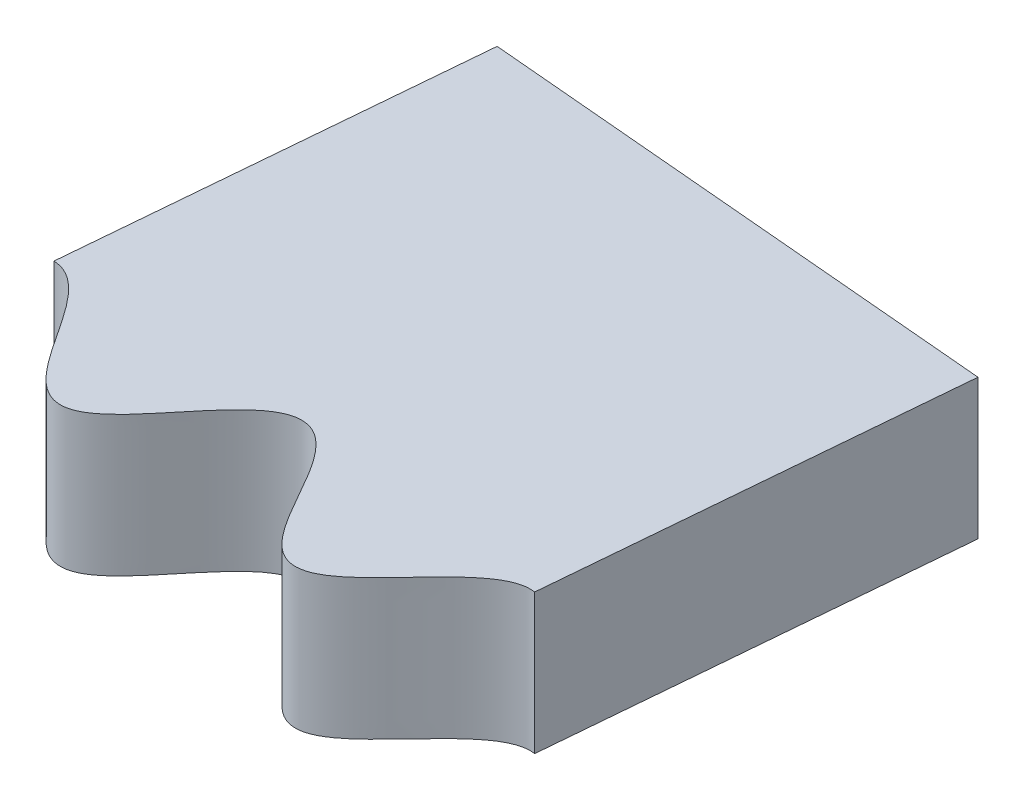
from build123d import *

# Parameters (mm, degrees)
BOSS_EXTRUDE1_DEPTH     = 3
CUT_EXTRUDE2_DEPTH      = 128.314571187
CUT_EXTRUDE2_DEPTH_BACK = 128.314571187
CUT_EXTRUDE1_DEPTH      = 128.295866017
CUT_EXTRUDE1_DEPTH_BACK = 128.295866017
CUT_EXTRUDE3_DEPTH      = 92.026378637
CUT_EXTRUDE3_DEPTH_BACK = 92.026378637


with BuildPart() as part:
    # Sketch1 → Boss-Extrude1 (new body)
    with BuildSketch(Plane(origin=(0, 0, 0), x_dir=(1, 0, 0), z_dir=(0, 1, 0))):
        with BuildLine():
            Line((0, 80.000000001), (0, 90))
            ThreePointArc((0, 90), (63.639610307, 63.639610307), (90, -1e-09))
            Line((90, -1e-09), (79.999999999, -1e-09))
            add(Edge.make_bspline(
                [(79.999999999, -1e-09), (80.041602972, 0.029584336), (80.124672232, 0.088800076), (80.35566562, 0.25503707), (80.580689493, 0.428196261), (80.814260212, 0.628581273), (81.018283416, 0.851310154), (81.156118968, 1.051783348), (81.240847827, 1.272600382), (81.246016609, 1.500136477), (81.179439654, 1.706446625), (81.07209396, 1.882262483), (80.890390613, 2.096864579), (80.621041115, 2.332166665), (80.269616736, 2.584320867), (79.89698522, 2.827334109), (79.578764204, 3.037245113), (79.320425686, 3.220223571), (79.121721967, 3.374962868), (78.93587352, 3.543581035), (78.772636972, 3.733120424), (78.655258727, 3.951437655), (78.623837197, 4.193153248), (78.683771621, 4.421996137), (78.795973828, 4.620716318), (78.984584589, 4.861193345), (79.260256827, 5.129313496), (79.614056753, 5.426162178), (80.034933667, 5.76565788), (80.383334353, 6.06905351), (80.649167813, 6.347378107), (80.823997795, 6.598345884), (80.921414714, 6.805042909), (80.956081181, 7.009003624), (80.930346945, 7.189278287), (80.859213533, 7.366686325), (80.74543326, 7.533712707), (80.581106495, 7.700842654), (80.324453775, 7.904792798), (79.998299986, 8.115192141), (79.608972322, 8.337012127), (79.219952007, 8.552844572), (78.892674068, 8.748998278), (78.645925583, 8.921468469), (78.475904629, 9.06187581), (78.334858688, 9.209053991), (78.228156562, 9.363513239), (78.155173948, 9.554557886), (78.14975415, 9.776640253), (78.224125666, 10.002339676), (78.352006258, 10.217315497), (78.505739265, 10.415655269), (78.674556444, 10.602546037), (78.897195956, 10.827604872), (79.174131916, 11.089585329), (79.498903567, 11.393613439), (79.801202691, 11.702961073), (80.025600841, 11.981460372), (80.167277182, 12.224354961), (80.242468586, 12.416137885), (80.271819819, 12.628249292), (80.229522961, 12.846179845), (80.114958566, 13.043632677), (79.954763586, 13.212416243), (79.720296673, 13.397936952), (79.407072243, 13.587360316), (79.021163378, 13.781984942), (78.568623274, 13.992615123), (78.180049511, 14.181676141), (77.861870541, 14.362378523), (77.620410558, 14.538567291), (77.4524268, 14.699555404), (77.324178924, 14.896997351), (77.274027441, 15.128431223), (77.311347079, 15.36116915), (77.402874813, 15.575335254), (77.557886287, 15.830947411), (77.78360241, 16.118944367), (78.072308852, 16.440385908), (78.413020362, 16.805019859), (78.698748429, 17.129144261), (78.919925661, 17.420606013), (79.070830749, 17.678529711), (79.160125782, 17.893107887), (79.199493517, 18.117666805), (79.166110239, 18.337116843), (79.066113718, 18.526654787), (78.928041203, 18.679890365), (78.758095072, 18.815824297), (78.563403249, 18.937780224), (78.292286179, 19.078874501), (77.942082175, 19.230391028), (77.586564332, 19.368174353), (77.231347041, 19.506941755), (76.94020429, 19.631303179), (76.713043974, 19.740085409), (76.495059022, 19.864369093), (76.293843643, 20.012665132), (76.133111284, 20.191926835), (76.044903013, 20.40380645), (76.037591525, 20.619301184), (76.082831408, 20.816111266), (76.1668516, 21.018822902), (76.283150762, 21.22615829), (76.464160702, 21.496087871), (76.715848982, 21.822467791), (77.019348776, 22.195304006), (77.308333885, 22.569732877), (77.525684963, 22.902766036), (77.662974453, 23.192900921), (77.732396667, 23.428451636), (77.738105043, 23.673858139), (77.654032855, 23.901813946), (77.501220488, 24.084150894), (77.316617591, 24.225367665), (77.056961817, 24.373272722), (76.719688349, 24.515101469), (76.310177073, 24.652935314), (75.832796036, 24.798363031), (75.42204772, 24.932385667), (75.082573555, 25.068940615), (74.820523526, 25.212801381), (74.634175149, 25.352510829), (74.485486428, 25.53540796), (74.41320195, 25.760911316), (74.425546896, 25.996024996), (74.490531041, 26.219436671), (74.611547136, 26.492750611), (74.796747016, 26.808332949), (75.038731258, 27.166351475), (75.325327393, 27.575032615), (75.562221961, 27.936536917), (75.738770592, 28.257194577), (75.849064541, 28.535093682), (75.90340568, 28.761362027), (75.90389494, 28.989643393), (75.831559817, 29.199525217), (75.700085201, 29.368543468), (75.539076071, 29.497036648), (75.294933474, 29.636551369), (74.9613493, 29.76553974), (74.544876821, 29.882293138), (74.11160217, 29.9832033), (73.740778506, 30.071617174), (73.435437361, 30.155203683), (73.195792994, 30.232650392), (72.963481769, 30.327535724), (72.7452633, 30.449814302), (72.560294939, 30.614819669), (72.448096758, 30.831211232), (72.426147815, 31.066751986), (72.463617097, 31.291863289), (72.55860525, 31.582346457), (72.725949925, 31.928582442), (72.956884876, 32.328535659), (73.236265438, 32.791505648), (73.459887575, 33.195764335), (73.614496696, 33.548224303), (73.692947106, 33.843852247), (73.71379452, 34.071402464), (73.67661167, 34.274919473), (73.590771832, 34.435520616), (73.463251167, 34.577900582), (73.299206297, 34.695938894), (73.08762784, 34.796786609), (72.776698116, 34.900656654), (72.398252994, 34.986816198), (71.956537757, 35.062100899), (71.517159194, 35.13186427), (71.142530011, 35.204252813), (70.851674001, 35.281928827), (70.643884426, 35.355717978), (70.461006694, 35.445779676), (70.307911319, 35.554429614), (70.173988978, 35.708991335), (70.09293939, 35.915826817), (70.085632007, 36.153351456), (70.132274394, 36.399100387), (70.208899969, 36.638058592), (70.303615819, 36.871417343), (70.435853871, 37.159050668), (70.606485955, 37.499949447), (70.807687742, 37.896720865), (70.985952875, 38.290804944), (71.101565791, 38.629257368), (71.151623161, 38.905959782), (71.156686345, 39.111893756), (71.111721108, 39.321251993), (70.997438424, 39.511573348), (70.822250262, 39.657934986), (70.613988842, 39.761749747), (70.330210194, 39.855889782), (69.971088903, 39.926760455), (69.541887647, 39.977659174), (69.044599286, 40.02080897), (68.614796712, 40.065568159), (68.254002427, 40.126549237), (67.966844156, 40.209528344), (67.75392988, 40.303353858), (67.565887175, 40.44502524), (67.439605148, 40.645349126), (67.395073085, 40.876815305), (67.407831866, 41.109369945), (67.466070637, 41.402583831), (67.579673265, 41.750411958), (67.741029898, 42.151211512), (67.93648042, 42.610385738), (68.094122342, 43.012687463), (68.202270425, 43.36221969), (68.255872092, 43.656199091), (68.266354226, 43.888385505), (68.224901916, 44.122650501), (68.104318197, 44.333580702), (67.912656635, 44.486952091), (67.68759058, 44.585180671), (67.37708638, 44.666505929), (66.9822576, 44.714074933), (66.509672397, 44.733377734), (66.028977379, 44.740537903), (65.617173747, 44.757526464), (65.294044745, 44.792372194), (65.060460963, 44.836554487), (64.851167702, 44.902491813), (64.671322796, 44.994343134), (64.510943987, 45.138461404), (64.405333968, 45.342226451), (64.371328306, 45.580581783), (64.387065702, 45.830044563), (64.431976903, 46.076918736), (64.494660716, 46.320857503), (64.586537291, 46.623823772), (64.708564568, 46.985133971), (64.831538881, 47.346041853), (64.940577283, 47.71170663), (65.006763489, 48.010088009), (65.03848532, 48.237622357), (65.043593155, 48.455185292), (65.014959193, 48.659452906), (64.93404123, 48.857887328), (64.787391105, 49.024520168), (64.590063902, 49.138706423), (64.36828974, 49.208230652), (64.073708805, 49.258420806), (63.708266165, 49.276337219), (63.276310007, 49.26579997), (62.777979057, 49.239181997), (62.346163627, 49.224638672), (61.980457633, 49.236850965), (61.685007905, 49.282409614), (61.462114258, 49.34995862), (61.259838062, 49.470971174), (61.114786181, 49.658152265), (61.045973022, 49.883309075), (61.03062685, 50.115473264), (61.050865909, 50.413694299), (61.116961353, 50.773586782), (61.221902611, 51.192777635), (61.351437703, 51.674833937), (61.450404027, 52.095559577), (61.506634094, 52.457262402), (61.515229412, 52.756124891), (61.488905048, 52.98733335), (61.411287976, 53.202015002), (61.271531383, 53.374499334), (61.09017801, 53.48835757), (60.894931662, 53.554033298), (60.617795822, 53.601632566), (60.260212614, 53.608749479), (59.828924485, 53.576019809), (59.387266184, 53.522655685), (59.008566597, 53.478908387), (58.693051506, 53.453021191), (58.441371129, 53.44383409), (58.19061729, 53.453542019), (57.943737267, 53.493811184), (57.713488707, 53.585602607), (57.53404662, 53.750570113), (57.432861723, 53.964399082), (57.391078572, 54.18874962), (57.380987624, 54.494202797), (57.419819196, 54.876792291), (57.500037766, 55.331612229), (57.604219792, 55.862211265), (57.676098978, 56.318580299), (57.700822788, 56.702652386), (57.67345467, 57.007304083), (57.615149416, 57.228200702), (57.493634223, 57.436206161), (57.293851917, 57.590987617), (57.045157934, 57.669958122), (56.778794714, 57.69580622), (56.4509512, 57.686944216), (56.065936692, 57.638539129), (55.625064093, 57.558166278), (55.188350987, 57.473471058), (54.811542785, 57.413351266), (54.511665947, 57.386868812), (54.291168979, 57.385138594), (54.088517381, 57.407221192), (53.907494346, 57.456957059), (53.728785281, 57.556393424), (53.581881676, 57.723034603), (53.493776775, 57.943735485), (53.453555195, 58.190616576), (53.443831164, 58.44137133), (53.453021555, 58.693051554), (53.478908286, 59.008566544), (53.522655747, 59.387266221), (53.576019764, 59.828924459), (53.608749501, 60.260212626), (53.601632559, 60.617795818), (53.5540333, 60.894931663), (53.48835757, 61.09017801), (53.374499335, 61.271531383), (53.202015003, 61.411287976), (52.98733335, 61.488905048), (52.756124892, 61.515229412), (52.457262402, 61.506634094), (52.095559577, 61.450404027), (51.674833937, 61.351437703), (51.192777635, 61.221902611), (50.773586782, 61.116961352), (50.413694299, 61.050865908), (50.115473264, 61.03062685), (49.883309075, 61.045973021), (49.658152265, 61.114786181), (49.470971173, 61.259838061), (49.349958626, 61.462114259), (49.282409587, 61.685007899), (49.236851076, 61.980457657), (49.224638401, 62.346163568), (49.239182517, 62.77797917), (49.265799096, 63.276309817), (49.276338753, 63.708266493), (49.258417646, 64.07370817), (49.208239861, 64.368291293), (49.138677413, 64.590060254), (49.019601636, 64.796019817), (48.834147627, 64.952987309), (48.601588568, 65.031557157), (48.356499504, 65.046884704), (48.036906122, 65.017106759), (47.649618873, 64.926767604), (47.198932099, 64.783272645), (46.744777615, 64.625593625), (46.351998351, 64.500712512), (46.03643847, 64.42294016), (45.80183028, 64.384567576), (45.582607053, 64.374945884), (45.38219312, 64.399747312), (45.182194986, 64.480321404), (45.01326228, 64.635677161), (44.899785085, 64.848027286), (44.829252104, 65.087828126), (44.787018888, 65.3351745), (44.762490433, 65.585841086), (44.745205605, 65.901959893), (44.736298371, 66.283216207), (44.728418661, 66.664418373), (44.705816522, 67.045324195), (44.66595877, 67.348347991), (44.61794621, 67.573009844), (44.548335098, 67.779199111), (44.451564338, 67.961354489), (44.307657755, 68.120146277), (44.112859927, 68.226572631), (43.888379011, 68.266382734), (43.656200781, 68.255862909), (43.362219206, 68.202273611), (43.01268768, 68.094120789), (42.610385617, 67.936481307), (42.151211584, 67.741029371), (41.750411921, 67.57967354), (41.402583847, 67.466070525), (41.109369942, 67.407831894), (40.876815306, 67.395073079), (40.645349126, 67.439605149), (40.445025241, 67.565887174), (40.303353858, 67.75392988), (40.209528344, 67.966844156), (40.126549237, 68.254002428), (40.06556816, 68.614796712), (40.02080897, 69.044599286), (39.977659175, 69.541887647), (39.926760456, 69.971088903), (39.855889782, 70.330210194), (39.761749748, 70.613988842), (39.657934987, 70.822250262), (39.511573348, 70.997438424), (39.321251993, 71.111721108), (39.111893756, 71.156686345), (38.905959782, 71.151623158), (38.629257369, 71.101565799), (38.29080494, 70.98595285), (37.896720874, 70.807687792), (37.499949433, 70.606485884), (37.159050683, 70.435853984), (36.871417423, 70.30361546), (36.638057403, 70.208902651), (36.399105564, 70.132262256), (36.153341363, 70.085664952), (35.905583975, 70.09317103), (35.680541359, 70.186816969), (35.512324844, 70.3531432), (35.396329122, 70.549673066), (35.282375593, 70.833253855), (35.188012021, 71.20605156), (35.107835239, 71.660878865), (35.024258761, 72.195111216), (34.935715699, 72.648541959), (34.827588091, 73.017907706), (34.697673456, 73.29482621), (34.567333345, 73.482459562), (34.382004358, 73.636360113), (34.141332024, 73.713477531), (33.88062662, 73.702627181), (33.621486498, 73.635814861), (33.31644535, 73.515358216), (32.971205573, 73.338189596), (32.584409979, 73.111876511), (32.203001367, 72.882924358), (31.86947966, 72.697554239), (31.596745141, 72.570104953), (31.390137537, 72.493064675), (31.192154633, 72.4445046), (31.005037951, 72.429327507), (30.803097128, 72.461645018), (30.608058255, 72.567992509), (30.449782586, 72.745249845), (30.327548, 72.963486109), (30.23265072, 73.195787647), (30.155191569, 73.435455455), (30.071652604, 73.740727262), (29.983124112, 74.111716393), (29.882440532, 74.54466436), (29.751508784, 75.010917506), (29.598303142, 75.389689457), (29.409589028, 75.668067135), (29.199483961, 75.831619263), (28.989655267, 75.903877833), (28.761359059, 75.903409957), (28.535094331, 75.849063606), (28.257194316, 75.73877097), (27.936537077, 75.562221732), (27.575032514, 75.325327539), (27.166351538, 75.038731168), (26.808332916, 74.796747064), (26.492750625, 74.611547117), (26.219436668, 74.490531046), (25.996024997, 74.425546895), (25.760911317, 74.413201951), (25.535407961, 74.485486428), (25.352510829, 74.63417515), (25.212801381, 74.820523526), (25.068940616, 75.082573555), (24.932385667, 75.42204772), (24.798363032, 75.832796036), (24.652935315, 76.310177073), (24.515101469, 76.719688349), (24.373272722, 77.056961817), (24.225367665, 77.316617591), (24.084150895, 77.501220489), (23.901813947, 77.654032856), (23.673858139, 77.738105043), (23.428451636, 77.732396667), (23.192900921, 77.662974453), (22.902766036, 77.525684963), (22.569732877, 77.308333886), (22.195304007, 77.019348776), (21.822467791, 76.715848983), (21.496087871, 76.464160702), (21.226158291, 76.283150762), (21.018822902, 76.166851601), (20.816111267, 76.082831408), (20.619301185, 76.037591525), (20.403806451, 76.044903014), (20.191926836, 76.133111284), (20.012665133, 76.293843643), (19.864369094, 76.495059023), (19.74008541, 76.713043975), (19.631303179, 76.94020429), (19.506941755, 77.231347041), (19.368174353, 77.586564332), (19.230391029, 77.942082175), (19.078874502, 78.292286179), (18.937780224, 78.563403249), (18.815824297, 78.758095072), (18.679890366, 78.928041203), (18.526654788, 79.066113718), (18.337116844, 79.166110239), (18.117666805, 79.199493518), (17.893107888, 79.160125783), (17.678529711, 79.070830749), (17.420606014, 78.919925661), (17.129144261, 78.69874843), (16.80501986, 78.413020362), (16.440385908, 78.072308852), (16.118944367, 77.78360241), (15.830947412, 77.557886287), (15.575335254, 77.402874813), (15.36116915, 77.311347079), (15.128431224, 77.274027441), (14.896997351, 77.324178924), (14.699555405, 77.452426801), (14.538567291, 77.620410559), (14.362378523, 77.861870542), (14.181676142, 78.180049511), (13.992615123, 78.568623275), (13.781984943, 79.021163379), (13.587360317, 79.407072244), (13.397936953, 79.720296673), (13.212416243, 79.954763586), (13.043632678, 80.114958566), (12.846179845, 80.229522961), (12.628249293, 80.271819819), (12.416137885, 80.242468587), (12.224354962, 80.16727718), (11.981460371, 80.02560085), (11.702961078, 79.801202666), (11.39361343, 79.498903618), (11.089585341, 79.174131844), (10.827604848, 78.897196068), (10.602546235, 78.674556134), (10.415653235, 78.505741379), (10.217324513, 78.351996623), (10.002318924, 78.224153173), (9.766935904, 78.146468561), (9.523436221, 78.157497852), (9.308477482, 78.256259948), (9.132259985, 78.401264738), (8.928188352, 78.628769112), (8.712011278, 78.946810118), (8.481109641, 79.346785914), (8.219855229, 79.82021526), (7.9815695, 80.216017294), (7.753632291, 80.526125704), (7.536840699, 80.741910627), (7.350186886, 80.873649116), (7.12339681, 80.954882885), (6.870865132, 80.945032435), (6.629587671, 80.845676267), (6.40894144, 80.694245416), (6.211128052, 80.519009442), (6.029457649, 80.332101133), (5.816457311, 80.09190662), (5.614074206, 79.846852317), (5.413538428, 79.600329501), (5.208468822, 79.357528606), (5.038559084, 79.168310476), (4.87078477, 79.000324827), (4.702993216, 78.857255698), (4.533557773, 78.743911453), (4.362916364, 78.665652164), (4.162100833, 78.626952836), (3.942451292, 78.660179508), (3.7330952, 78.772613498), (3.543591665, 78.935881709), (3.374959826, 79.12171778), (3.2202265, 79.320435777), (3.037237307, 79.578735654), (2.827352032, 79.897050875), (2.619008751, 80.21628), (2.39906785, 80.527958221), (2.206288538, 80.765002448), (2.04825606, 80.931612231), (1.882258293, 81.072078605), (1.706447202, 81.179441768), (1.500136496, 81.246016677), (1.27260037, 81.240847779), (1.051783338, 81.156118931), (0.851310168, 81.01828346), (0.62858125, 80.814260161), (0.428196313, 80.580689584), (0.255036967, 80.355665447), (0.088800204, 80.124672445), (0.029584337, 80.041602974), (0, 80.000000001)],
                knots=[0.077847526, 0.077847526, 0.077847526, 0.077847526, 0.077847526, 0.079019089, 0.080190652, 0.082533779, 0.083705342, 0.084876905, 0.086048468, 0.087220031, 0.088210559, 0.089201086, 0.090191614, 0.091182141, 0.093644505, 0.096106868, 0.098569231, 0.099800413, 0.101031595, 0.102239172, 0.10344675, 0.104654328, 0.105861906, 0.106959082, 0.108056259, 0.109153436, 0.110250612, 0.112868894, 0.115487176, 0.118105457, 0.120723739, 0.12182072, 0.122917702, 0.124014684, 0.125111666, 0.125758009, 0.126404352, 0.127697039, 0.128989725, 0.130282411, 0.132745478, 0.135208544, 0.13767161, 0.138903144, 0.140134677, 0.141036522, 0.141938367, 0.142840212, 0.143742057, 0.144949635, 0.146157213, 0.147364791, 0.148572368, 0.14980355, 0.151034732, 0.153497095, 0.155959458, 0.158421822, 0.159412349, 0.160402877, 0.161393404, 0.162383932, 0.163504677, 0.164625422, 0.165746167, 0.166866913, 0.169284472, 0.171702032, 0.174119591, 0.176537151, 0.177658304, 0.178779457, 0.17990061, 0.181021763, 0.182142924, 0.183264084, 0.184385245, 0.185506405, 0.187923426, 0.190340446, 0.192757467, 0.195174487, 0.196294788, 0.197415089, 0.198535391, 0.199655692, 0.200646634, 0.201637576, 0.202628519, 0.203619461, 0.204850906, 0.206082351, 0.208545241, 0.211008132, 0.212239577, 0.213471022, 0.214678537, 0.215886051, 0.217093566, 0.21830108, 0.219270311, 0.220239542, 0.221208773, 0.222178004, 0.223508612, 0.22483922, 0.227500436, 0.230161653, 0.232822869, 0.234003972, 0.235185075, 0.236366178, 0.23754728, 0.238667582, 0.239787883, 0.240908184, 0.242028485, 0.244445506, 0.246862526, 0.249279546, 0.251696567, 0.252817727, 0.253938888, 0.255060048, 0.256181209, 0.257302362, 0.258423515, 0.259544668, 0.260665822, 0.263083381, 0.265500941, 0.2679185, 0.27033606, 0.271456805, 0.27257755, 0.273698295, 0.274819041, 0.275809568, 0.276800096, 0.277790623, 0.278781151, 0.281243514, 0.283705877, 0.28616824, 0.287399422, 0.288630604, 0.289838182, 0.291045759, 0.292253337, 0.293460915, 0.294558091, 0.295655268, 0.296752445, 0.297849622, 0.300467903, 0.303086185, 0.305704466, 0.308322748, 0.30941973, 0.310516712, 0.311613693, 0.312710675, 0.313357018, 0.314003362, 0.315296048, 0.316588734, 0.317881421, 0.320344487, 0.322807553, 0.32527062, 0.326502153, 0.327733686, 0.328635531, 0.329537376, 0.330439222, 0.331341067, 0.332548644, 0.333756222, 0.3349638, 0.336171378, 0.337402559, 0.338633741, 0.341096104, 0.343558468, 0.346020831, 0.347011358, 0.348001886, 0.348992413, 0.349982941, 0.351103686, 0.352224431, 0.353345177, 0.354465922, 0.356883481, 0.359301041, 0.3617186, 0.36413616, 0.365257313, 0.366378466, 0.367499619, 0.368620773, 0.369741933, 0.370863094, 0.371984254, 0.373105415, 0.375522435, 0.377939455, 0.380356476, 0.382773496, 0.383893797, 0.385014099, 0.3861344, 0.387254701, 0.388435804, 0.389616907, 0.39079801, 0.391979112, 0.394640329, 0.397301545, 0.399962762, 0.40129337, 0.402623978, 0.403593209, 0.40456244, 0.40553167, 0.406500901, 0.407708416, 0.40891593, 0.410123445, 0.41133096, 0.412562405, 0.41379385, 0.41625674, 0.41871963, 0.419951075, 0.42118252, 0.422173463, 0.423164405, 0.424155347, 0.42514629, 0.426266591, 0.427386892, 0.428507193, 0.429627494, 0.432044515, 0.434461535, 0.436878556, 0.439295576, 0.440416737, 0.441537897, 0.442659058, 0.443780218, 0.444901371, 0.446022525, 0.447143678, 0.448264831, 0.45068239, 0.45309995, 0.455517509, 0.457935069, 0.459055814, 0.460176559, 0.461297305, 0.46241805, 0.463408577, 0.464399105, 0.465389632, 0.46638016, 0.468842523, 0.471304886, 0.47376725, 0.474998431, 0.476229613, 0.477437191, 0.478644769, 0.479852346, 0.481059924, 0.482157101, 0.483254277, 0.484351454, 0.485448631, 0.488066912, 0.490685194, 0.493303476, 0.495921757, 0.497018739, 0.498115721, 0.499212703, 0.500309685, 0.501602371, 0.502895057, 0.504187743, 0.50548043, 0.507943496, 0.510406563, 0.512869629, 0.514101162, 0.515332695, 0.51623454, 0.517136386, 0.518038231, 0.518940076, 0.520147654, 0.521355231, 0.522562809, 0.523770387, 0.525001569, 0.52623275, 0.528695114, 0.531157477, 0.53361984, 0.534610368, 0.535600895, 0.536591423, 0.53758195, 0.538702695, 0.539823441, 0.540944186, 0.542064931, 0.544482491, 0.54690005, 0.54931761, 0.551735169, 0.552856322, 0.553977475, 0.555098629, 0.556219782, 0.557340942, 0.558462103, 0.559583263, 0.560704424, 0.563121444, 0.565538465, 0.567955485, 0.570372506, 0.571492807, 0.572613108, 0.573733409, 0.57485371, 0.576034813, 0.577215916, 0.578397019, 0.579578122, 0.582239338, 0.584900554, 0.587561771, 0.588892379, 0.590222987, 0.591192218, 0.592161449, 0.59313068, 0.59409991, 0.595307425, 0.59651494, 0.597722454, 0.598929969, 0.600161414, 0.601392859, 0.603855749, 0.60631864, 0.607550085, 0.60878153, 0.609772472, 0.610763414, 0.611754357, 0.612745299, 0.6138656, 0.614985901, 0.616106203, 0.617226504, 0.619643524, 0.622060545, 0.624477565, 0.626894585, 0.628015746, 0.629136906, 0.630258067, 0.631379227, 0.632500381, 0.633621534, 0.634742687, 0.63586384, 0.6382814, 0.640698959, 0.643116519, 0.645534078, 0.646654823, 0.647775569, 0.648896314, 0.650017059, 0.651007587, 0.651998114, 0.652988642, 0.653979169, 0.656441532, 0.658903896, 0.661366259, 0.662597441, 0.663828622, 0.6650362, 0.666243778, 0.667451356, 0.668658933, 0.66975611, 0.670853287, 0.671950463, 0.67304764, 0.675665922, 0.678284203, 0.680902485, 0.683520766, 0.684617748, 0.68571473, 0.686811712, 0.687908694, 0.68920138, 0.690494066, 0.691786753, 0.693079439, 0.695542505, 0.698005572, 0.700468638, 0.701700171, 0.702931705, 0.70383355, 0.704735395, 0.70563724, 0.706539085, 0.707746663, 0.708954241, 0.710161818, 0.711369396, 0.712600578, 0.71383176, 0.716294123, 0.718756486, 0.721218849, 0.723199904, 0.724190432, 0.725180959, 0.726301705, 0.72742245, 0.728543195, 0.72966394, 0.7320815, 0.734499059, 0.736916619, 0.739334178, 0.740455332, 0.741576485, 0.742697638, 0.743818791, 0.744939952, 0.746061112, 0.747182273, 0.748303433, 0.750720454, 0.753137474, 0.755554494, 0.757971515, 0.759091816, 0.760212117, 0.761332418, 0.76245272, 0.763633822, 0.764814925, 0.765996028, 0.767177131, 0.769838347, 0.772499564, 0.77516078, 0.776491388, 0.777821996, 0.778791227, 0.779760458, 0.780729689, 0.78169892, 0.782906434, 0.784113949, 0.785321463, 0.786528978, 0.787760423, 0.788991868, 0.791454759, 0.793917649, 0.795149094, 0.796380539, 0.797371481, 0.798362424, 0.799353366, 0.800344308, 0.801464609, 0.802584911, 0.803705212, 0.804825513, 0.807242533, 0.809659554, 0.812076574, 0.814493595, 0.815614755, 0.816735916, 0.817857076, 0.818978237, 0.82009939, 0.821220543, 0.822341696, 0.823462849, 0.825880409, 0.828297968, 0.830715528, 0.833133087, 0.834253833, 0.835374578, 0.836495323, 0.837616068, 0.838606596, 0.839597123, 0.840587651, 0.841578178, 0.844040542, 0.846502905, 0.848965268, 0.85019645, 0.851427632, 0.852635209, 0.853842787, 0.855050365, 0.856257943, 0.857355119, 0.858452296, 0.859549473, 0.860646649, 0.863264931, 0.865883212, 0.868501494, 0.871119776, 0.872216757, 0.873313739, 0.874410721, 0.875507703, 0.876800389, 0.878093076, 0.879385762, 0.880678448, 0.881909981, 0.883141515, 0.885604581, 0.886836114, 0.888067647, 0.889299181, 0.890530714, 0.891432559, 0.892334404, 0.893236249, 0.894138094, 0.895345672, 0.89655325, 0.897760828, 0.898968405, 0.900199587, 0.901430769, 0.903893132, 0.906355495, 0.907586677, 0.908817859, 0.909808386, 0.910798914, 0.911789441, 0.912779969, 0.913951532, 0.915123095, 0.916294658, 0.917466221, 0.919809348, 0.920980911, 0.922152474, 0.922152474, 0.922152474, 0.922152474, 0.922152474], degree=4))
        make_face()
    extrude(amount=BOSS_EXTRUDE1_DEPTH)

    # Sketch3 → Cut-Extrude2 (cut, two sides)
    with BuildSketch(Plane(origin=(0, 3, 0), x_dir=(1, 0, 0), z_dir=(0, 1, 0))) as cut_extrude2_sk:
        with BuildLine():
            Line((1.418002739, 81.237322491), (2.182322522, 89.973537601))
            ThreePointArc((2.182322522, 89.973537601), (1.091241478, 89.993384157), (0, 90))
            Line((0, 90), (0, 80.000000001))
            add(Edge.make_bspline(
                [(0, 80.000000001), (0.029584337, 80.041602974), (0.088800204, 80.124672445), (0.255036967, 80.355665447), (0.428196313, 80.580689584), (0.62858125, 80.814260161), (0.851310168, 81.01828346), (1.051783338, 81.156118931), (1.22708417, 81.223382935), (1.351218774, 81.238056655), (1.41481254, 81.237377239), (1.418002739, 81.237322491)],
                knots=[0.077847526, 0.077847526, 0.077847526, 0.077847526, 0.077847526, 0.079019089, 0.080190652, 0.082533779, 0.083705342, 0.084876905, 0.086048468, 0.087220031, 0.087281915, 0.087281915, 0.087281915, 0.087281915, 0.087281915], degree=4))
        make_face()
    extrude(amount=CUT_EXTRUDE2_DEPTH, mode=Mode.SUBTRACT)
    extrude(cut_extrude2_sk.sketch, amount=-CUT_EXTRUDE2_DEPTH_BACK, mode=Mode.SUBTRACT)

    # Sketch2 → Cut-Extrude1 (cut, two sides)
    with BuildSketch(Plane(origin=(0, 3, 0), x_dir=(1, 0, 0), z_dir=(0, 1, 0))) as cut_extrude1_sk:
        with BuildLine():
            Line((13.474573019, 88.985593677), (12.710253656, 80.249384336))
            add(Edge.make_bspline(
                [(12.710253656, 80.249384336), (12.713404224, 80.248884632), (12.773562237, 80.238943153), (12.888306084, 80.205080835), (13.043632678, 80.114958566), (13.212416243, 79.954763586), (13.397936953, 79.720296673), (13.587360317, 79.407072244), (13.781984943, 79.021163379), (13.992615123, 78.568623275), (14.181676142, 78.180049511), (14.362378523, 77.861870542), (14.538567291, 77.620410559), (14.699555405, 77.452426801), (14.896997351, 77.324178924), (15.128431224, 77.274027441), (15.36116915, 77.311347079), (15.575335254, 77.402874813), (15.830947412, 77.557886287), (16.118944367, 77.78360241), (16.440385908, 78.072308852), (16.80501986, 78.413020362), (17.129144261, 78.69874843), (17.420606014, 78.919925661), (17.678529711, 79.070830749), (17.893107888, 79.160125783), (18.117666805, 79.199493518), (18.337116844, 79.166110239), (18.526654788, 79.066113718), (18.679890366, 78.928041203), (18.815824297, 78.758095072), (18.937780224, 78.563403249), (19.078874502, 78.292286179), (19.230391029, 77.942082175), (19.368174353, 77.586564332), (19.506941755, 77.231347041), (19.631303179, 76.94020429), (19.74008541, 76.713043975), (19.864369094, 76.495059023), (20.012665133, 76.293843643), (20.191926836, 76.133111284), (20.403806451, 76.044903014), (20.619301185, 76.037591525), (20.816111267, 76.082831408), (21.018822902, 76.166851601), (21.226158291, 76.283150762), (21.496087871, 76.464160702), (21.822467791, 76.715848983), (22.195304007, 77.019348776), (22.569732877, 77.308333886), (22.902766036, 77.525684963), (23.192900921, 77.662974453), (23.428451636, 77.732396667), (23.673858139, 77.738105043), (23.901813947, 77.654032856), (24.084150895, 77.501220489), (24.225367665, 77.316617591), (24.373272722, 77.056961817), (24.515101469, 76.719688349), (24.652935315, 76.310177073), (24.798363032, 75.832796036), (24.932385667, 75.42204772), (25.068940616, 75.082573555), (25.212801381, 74.820523526), (25.352510829, 74.63417515), (25.535407961, 74.485486428), (25.760911317, 74.413201951), (25.996024997, 74.425546895), (26.219436668, 74.490531046), (26.492750625, 74.611547117), (26.808332916, 74.796747064), (27.166351538, 75.038731168), (27.575032514, 75.325327539), (27.936537077, 75.562221732), (28.257194316, 75.73877097), (28.535094331, 75.849063606), (28.761359059, 75.903409957), (28.989655267, 75.903877833), (29.199483961, 75.831619263), (29.409589028, 75.668067135), (29.598303142, 75.389689457), (29.751508784, 75.010917506), (29.882440532, 74.54466436), (29.983124112, 74.111716393), (30.071652604, 73.740727262), (30.155191569, 73.435455455), (30.23265072, 73.195787647), (30.327548, 72.963486109), (30.449782586, 72.745249845), (30.608058255, 72.567992509), (30.803097128, 72.461645018), (31.005037951, 72.429327507), (31.192154633, 72.4445046), (31.390137537, 72.493064675), (31.596745141, 72.570104953), (31.86947966, 72.697554239), (32.203001367, 72.882924358), (32.584409979, 73.111876511), (32.971205573, 73.338189596), (33.31644535, 73.515358216), (33.621486498, 73.635814861), (33.88062662, 73.702627181), (34.141332024, 73.713477531), (34.382004358, 73.636360113), (34.567333345, 73.482459562), (34.697673456, 73.29482621), (34.827588091, 73.017907706), (34.935715699, 72.648541959), (35.024258761, 72.195111216), (35.107835239, 71.660878865), (35.188012021, 71.20605156), (35.282375593, 70.833253855), (35.396329122, 70.549673066), (35.512324844, 70.3531432), (35.680541359, 70.186816969), (35.905583975, 70.09317103), (36.153341363, 70.085664952), (36.399105564, 70.132262256), (36.638057403, 70.208902651), (36.871417423, 70.30361546), (37.159050683, 70.435853984), (37.499949433, 70.606485884), (37.896720874, 70.807687792), (38.29080494, 70.98595285), (38.629257369, 71.101565799), (38.905959782, 71.151623158), (39.111893756, 71.156686345), (39.321251993, 71.111721108), (39.511573348, 70.997438424), (39.657934987, 70.822250262), (39.761749748, 70.613988842), (39.855889782, 70.330210194), (39.926760456, 69.971088903), (39.977659175, 69.541887647), (40.02080897, 69.044599286), (40.06556816, 68.614796712), (40.126549237, 68.254002428), (40.209528344, 67.966844156), (40.303353858, 67.75392988), (40.445025241, 67.565887174), (40.645349126, 67.439605149), (40.876815306, 67.395073079), (41.109369942, 67.407831894), (41.402583847, 67.466070525), (41.750411921, 67.57967354), (42.151211584, 67.741029371), (42.610385617, 67.936481307), (43.01268768, 68.094120789), (43.362219206, 68.202273611), (43.656200781, 68.255862909), (43.888379011, 68.266382734), (44.112859927, 68.226572631), (44.307657755, 68.120146277), (44.451564338, 67.961354489), (44.548335098, 67.779199111), (44.61794621, 67.573009844), (44.66595877, 67.348347991), (44.705816522, 67.045324195), (44.728418661, 66.664418373), (44.736298371, 66.283216207), (44.745205605, 65.901959893), (44.762490433, 65.585841086), (44.787018888, 65.3351745), (44.829252104, 65.087828126), (44.899785085, 64.848027286), (45.01326228, 64.635677161), (45.182194986, 64.480321404), (45.38219312, 64.399747312), (45.582607053, 64.374945884), (45.80183028, 64.384567576), (46.03643847, 64.42294016), (46.351998351, 64.500712512), (46.744777615, 64.625593625), (47.198932099, 64.783272645), (47.649618873, 64.926767604), (48.036906122, 65.017106759), (48.356499504, 65.046884704), (48.601588568, 65.031557157), (48.834147627, 64.952987309), (49.019601636, 64.796019817), (49.138677413, 64.590060254), (49.208239861, 64.368291293), (49.258417646, 64.07370817), (49.276338753, 63.708266493), (49.265799096, 63.276309817), (49.239182517, 62.77797917), (49.224638401, 62.346163568), (49.236851076, 61.980457657), (49.282409587, 61.685007899), (49.349958626, 61.462114259), (49.470971173, 61.259838061), (49.658152265, 61.114786181), (49.883309075, 61.045973021), (50.115473264, 61.03062685), (50.413694299, 61.050865908), (50.773586782, 61.116961352), (51.192777635, 61.221902611), (51.674833937, 61.351437703), (52.095559577, 61.450404027), (52.457262402, 61.506634094), (52.756124892, 61.515229412), (52.98733335, 61.488905048), (53.202015003, 61.411287976), (53.374499335, 61.271531383), (53.48835757, 61.09017801), (53.5540333, 60.894931663), (53.601632559, 60.617795818), (53.608749501, 60.260212626), (53.576019764, 59.828924459), (53.522655747, 59.387266221), (53.478908286, 59.008566544), (53.453021555, 58.693051554), (53.443831164, 58.44137133), (53.453555195, 58.190616576), (53.493776775, 57.943735485), (53.581881676, 57.723034603), (53.728785281, 57.556393424), (53.907494346, 57.456957059), (54.088517381, 57.407221192), (54.291168979, 57.385138594), (54.511665947, 57.386868812), (54.811542785, 57.413351266), (55.188350987, 57.473471058), (55.625064093, 57.558166278), (56.065936692, 57.638539129), (56.4509512, 57.686944216), (56.778794714, 57.69580622), (57.045157934, 57.669958122), (57.293851917, 57.590987617), (57.493634223, 57.436206161), (57.615149416, 57.228200702), (57.67345467, 57.007304083), (57.700822788, 56.702652386), (57.676098978, 56.318580299), (57.604219792, 55.862211265), (57.500037766, 55.331612229), (57.419819196, 54.876792291), (57.380987624, 54.494202797), (57.391078572, 54.18874962), (57.432861723, 53.964399082), (57.53404662, 53.750570113), (57.713488707, 53.585602607), (57.943737267, 53.493811184), (58.19061729, 53.453542019), (58.441371129, 53.44383409), (58.693051506, 53.453021191), (59.008566597, 53.478908387), (59.387266184, 53.522655685), (59.828924485, 53.576019809), (60.260212614, 53.608749479), (60.617795822, 53.601632566), (60.894931662, 53.554033298), (61.09017801, 53.48835757), (61.271531383, 53.374499334), (61.411287976, 53.202015002), (61.488905048, 52.98733335), (61.515229412, 52.756124891), (61.506634094, 52.457262402), (61.450404027, 52.095559577), (61.351437703, 51.674833937), (61.221902611, 51.192777635), (61.116961353, 50.773586782), (61.050865909, 50.413694299), (61.03062685, 50.115473264), (61.045973022, 49.883309075), (61.114786181, 49.658152265), (61.259838062, 49.470971174), (61.462114258, 49.34995862), (61.685007905, 49.282409614), (61.980457633, 49.236850965), (62.346163627, 49.224638672), (62.777979057, 49.239181997), (63.276310007, 49.26579997), (63.708266165, 49.276337219), (64.073708805, 49.258420806), (64.36828974, 49.208230652), (64.590063902, 49.138706423), (64.787391105, 49.024520168), (64.93404123, 48.857887328), (65.014959193, 48.659452906), (65.043593155, 48.455185292), (65.03848532, 48.237622357), (65.006763489, 48.010088009), (64.940577283, 47.71170663), (64.831538881, 47.346041853), (64.708564568, 46.985133971), (64.586537291, 46.623823772), (64.494660716, 46.320857503), (64.431976903, 46.076918736), (64.387065702, 45.830044563), (64.371328306, 45.580581783), (64.405333968, 45.342226451), (64.510943987, 45.138461404), (64.671322796, 44.994343134), (64.851167702, 44.902491813), (65.060460963, 44.836554487), (65.294044745, 44.792372194), (65.617173747, 44.757526464), (66.028977379, 44.740537903), (66.509672397, 44.733377734), (66.9822576, 44.714074933), (67.37708638, 44.666505929), (67.68759058, 44.585180671), (67.912656635, 44.486952091), (68.104318197, 44.333580702), (68.224901916, 44.122650501), (68.266354226, 43.888385505), (68.255872092, 43.656199091), (68.202270425, 43.36221969), (68.094122342, 43.012687463), (67.93648042, 42.610385738), (67.741029898, 42.151211512), (67.579673265, 41.750411958), (67.466070637, 41.402583831), (67.407831866, 41.109369945), (67.395073085, 40.876815305), (67.439605148, 40.645349126), (67.565887175, 40.44502524), (67.75392988, 40.303353858), (67.966844156, 40.209528344), (68.254002427, 40.126549237), (68.614796712, 40.065568159), (69.044599286, 40.02080897), (69.541887647, 39.977659174), (69.971088903, 39.926760455), (70.330210194, 39.855889782), (70.613988842, 39.761749747), (70.822250262, 39.657934986), (70.997438424, 39.511573348), (71.111721108, 39.321251993), (71.156686345, 39.111893756), (71.151623161, 38.905959782), (71.101565791, 38.629257368), (70.985952875, 38.290804944), (70.807687742, 37.896720865), (70.606485955, 37.499949447), (70.435853871, 37.159050668), (70.303615819, 36.871417343), (70.208899969, 36.638058592), (70.132274394, 36.399100387), (70.085632007, 36.153351456), (70.09293939, 35.915826817), (70.173988978, 35.708991335), (70.307911319, 35.554429614), (70.461006694, 35.445779676), (70.643884426, 35.355717978), (70.851674001, 35.281928827), (71.142530011, 35.204252813), (71.517159194, 35.13186427), (71.956537757, 35.062100899), (72.398252994, 34.986816198), (72.776698116, 34.900656654), (73.08762784, 34.796786609), (73.299206297, 34.695938894), (73.463251167, 34.577900582), (73.590771832, 34.435520616), (73.67661167, 34.274919473), (73.71379452, 34.071402464), (73.692947106, 33.843852247), (73.614496696, 33.548224303), (73.459887575, 33.195764335), (73.236265438, 32.791505648), (72.956884876, 32.328535659), (72.725949925, 31.928582442), (72.55860525, 31.582346457), (72.463617097, 31.291863289), (72.426147815, 31.066751986), (72.448096758, 30.831211232), (72.560294939, 30.614819669), (72.7452633, 30.449814302), (72.963481769, 30.327535724), (73.195792994, 30.232650392), (73.435437361, 30.155203683), (73.740778506, 30.071617174), (74.11160217, 29.9832033), (74.544876821, 29.882293138), (74.9613493, 29.76553974), (75.294933474, 29.636551369), (75.539076071, 29.497036648), (75.700085201, 29.368543468), (75.831559817, 29.199525217), (75.90389494, 28.989643393), (75.90340568, 28.761362027), (75.849064541, 28.535093682), (75.738770592, 28.257194577), (75.562221961, 27.936536917), (75.325327393, 27.575032615), (75.038731258, 27.166351475), (74.796747016, 26.808332949), (74.611547136, 26.492750611), (74.490531041, 26.219436671), (74.425546896, 25.996024996), (74.41320195, 25.760911316), (74.485486428, 25.53540796), (74.634175149, 25.352510829), (74.820523526, 25.212801381), (75.082573555, 25.068940615), (75.42204772, 24.932385667), (75.832796036, 24.798363031), (76.310177073, 24.652935314), (76.719688349, 24.515101469), (77.056961817, 24.373272722), (77.316617591, 24.225367665), (77.501220488, 24.084150894), (77.654032855, 23.901813946), (77.738105043, 23.673858139), (77.732396667, 23.428451636), (77.662974453, 23.192900921), (77.525684963, 22.902766036), (77.308333885, 22.569732877), (77.019348776, 22.195304006), (76.715848982, 21.822467791), (76.464160702, 21.496087871), (76.283150762, 21.22615829), (76.1668516, 21.018822902), (76.082831408, 20.816111266), (76.037591525, 20.619301184), (76.044903013, 20.40380645), (76.133111284, 20.191926835), (76.293843643, 20.012665132), (76.495059022, 19.864369093), (76.713043974, 19.740085409), (76.94020429, 19.631303179), (77.231347041, 19.506941755), (77.586564332, 19.368174353), (77.942082175, 19.230391028), (78.292286179, 19.078874501), (78.563403249, 18.937780224), (78.758095072, 18.815824297), (78.928041203, 18.679890365), (79.066113718, 18.526654787), (79.166110239, 18.337116843), (79.199493517, 18.117666805), (79.160125782, 17.893107887), (79.070830749, 17.678529711), (78.919925661, 17.420606013), (78.698748429, 17.129144261), (78.413020362, 16.805019859), (78.072308852, 16.440385908), (77.78360241, 16.118944367), (77.557886287, 15.830947411), (77.402874813, 15.575335254), (77.311347079, 15.36116915), (77.274027441, 15.128431223), (77.324178924, 14.896997351), (77.4524268, 14.699555404), (77.620410558, 14.538567291), (77.861870541, 14.362378523), (78.180049511, 14.181676141), (78.568623274, 13.992615123), (79.021163378, 13.781984942), (79.407072243, 13.587360316), (79.720296673, 13.397936952), (79.954763586, 13.212416243), (80.114958566, 13.043632677), (80.229522961, 12.846179845), (80.271819819, 12.628249292), (80.242468586, 12.416137885), (80.167277182, 12.224354961), (80.025600841, 11.981460372), (79.801202691, 11.702961073), (79.498903567, 11.393613439), (79.174131916, 11.089585329), (78.897195956, 10.827604872), (78.674556444, 10.602546037), (78.505739265, 10.415655269), (78.352006258, 10.217315497), (78.224125666, 10.002339676), (78.14975415, 9.776640253), (78.155173948, 9.554557886), (78.228156562, 9.363513239), (78.334858688, 9.209053991), (78.475904629, 9.06187581), (78.645925583, 8.921468469), (78.892674068, 8.748998278), (79.219952007, 8.552844572), (79.608972322, 8.337012127), (79.998299986, 8.115192141), (80.324453775, 7.904792798), (80.581106495, 7.700842654), (80.74543326, 7.533712707), (80.859213533, 7.366686325), (80.930346945, 7.189278287), (80.956081181, 7.009003624), (80.921414714, 6.805042909), (80.823997795, 6.598345884), (80.649167813, 6.347378107), (80.383334353, 6.06905351), (80.034933667, 5.76565788), (79.614056753, 5.426162178), (79.260256827, 5.129313496), (78.984584589, 4.861193345), (78.795973828, 4.620716318), (78.683771621, 4.421996137), (78.623837197, 4.193153248), (78.655258727, 3.951437655), (78.772636972, 3.733120424), (78.93587352, 3.543581035), (79.121721967, 3.374962868), (79.320425686, 3.220223571), (79.578764204, 3.037245113), (79.89698522, 2.827334109), (80.269616736, 2.584320867), (80.621041115, 2.332166665), (80.890390613, 2.096864579), (81.07209396, 1.882262483), (81.179439654, 1.706446625), (81.246016609, 1.500136477), (81.240847827, 1.272600382), (81.156118968, 1.051783348), (81.018283416, 0.851310154), (80.814260212, 0.628581273), (80.580689493, 0.428196261), (80.35566562, 0.25503707), (80.124672232, 0.088800076), (80.041602972, 0.029584336), (79.999999999, -1e-09)],
                knots=[0.162322059, 0.162322059, 0.162322059, 0.162322059, 0.162322059, 0.162383932, 0.163504677, 0.164625422, 0.165746167, 0.166866913, 0.169284472, 0.171702032, 0.174119591, 0.176537151, 0.177658304, 0.178779457, 0.17990061, 0.181021763, 0.182142924, 0.183264084, 0.184385245, 0.185506405, 0.187923426, 0.190340446, 0.192757467, 0.195174487, 0.196294788, 0.197415089, 0.198535391, 0.199655692, 0.200646634, 0.201637576, 0.202628519, 0.203619461, 0.204850906, 0.206082351, 0.208545241, 0.211008132, 0.212239577, 0.213471022, 0.214678537, 0.215886051, 0.217093566, 0.21830108, 0.219270311, 0.220239542, 0.221208773, 0.222178004, 0.223508612, 0.22483922, 0.227500436, 0.230161653, 0.232822869, 0.234003972, 0.235185075, 0.236366178, 0.23754728, 0.238667582, 0.239787883, 0.240908184, 0.242028485, 0.244445506, 0.246862526, 0.249279546, 0.251696567, 0.252817727, 0.253938888, 0.255060048, 0.256181209, 0.257302362, 0.258423515, 0.259544668, 0.260665822, 0.263083381, 0.265500941, 0.2679185, 0.27033606, 0.271456805, 0.27257755, 0.273698295, 0.274819041, 0.275809568, 0.276800096, 0.278781151, 0.281243514, 0.283705877, 0.28616824, 0.287399422, 0.288630604, 0.289838182, 0.291045759, 0.292253337, 0.293460915, 0.29436276, 0.295264605, 0.29616645, 0.297068295, 0.298299829, 0.299531362, 0.301994428, 0.304457495, 0.306920561, 0.308213247, 0.309505934, 0.31079862, 0.312091306, 0.313188288, 0.31428527, 0.315382252, 0.316479234, 0.319097515, 0.321715797, 0.324334078, 0.32695236, 0.328049537, 0.329146713, 0.33024389, 0.331341067, 0.332548644, 0.333756222, 0.3349638, 0.336171378, 0.337402559, 0.338633741, 0.341096104, 0.343558468, 0.346020831, 0.347011358, 0.348001886, 0.348992413, 0.349982941, 0.351103686, 0.352224431, 0.353345177, 0.354465922, 0.356883481, 0.359301041, 0.3617186, 0.36413616, 0.365257313, 0.366378466, 0.367499619, 0.368620773, 0.369741933, 0.370863094, 0.371984254, 0.373105415, 0.375522435, 0.377939455, 0.380356476, 0.382773496, 0.383893797, 0.385014099, 0.3861344, 0.387254701, 0.388245643, 0.389236586, 0.390227528, 0.39121847, 0.392449915, 0.39368136, 0.396144251, 0.398607141, 0.399838586, 0.401070031, 0.402277546, 0.40348506, 0.404692575, 0.40590009, 0.40686932, 0.407838551, 0.408807782, 0.409777013, 0.411107621, 0.412438229, 0.415099446, 0.417760662, 0.420421878, 0.421602981, 0.422784084, 0.423965187, 0.42514629, 0.426266591, 0.427386892, 0.428507193, 0.429627494, 0.432044515, 0.434461535, 0.436878556, 0.439295576, 0.440416737, 0.441537897, 0.442659058, 0.443780218, 0.444901371, 0.446022525, 0.447143678, 0.448264831, 0.45068239, 0.45309995, 0.455517509, 0.457935069, 0.459055814, 0.460176559, 0.461297305, 0.46241805, 0.463408577, 0.464399105, 0.465389632, 0.46638016, 0.468842523, 0.471304886, 0.47376725, 0.474998431, 0.476229613, 0.477437191, 0.478644769, 0.479852346, 0.481059924, 0.481961769, 0.482863614, 0.48376546, 0.484667305, 0.485898838, 0.487130371, 0.489593437, 0.492056504, 0.49451957, 0.495812257, 0.497104943, 0.498397629, 0.499690315, 0.500787297, 0.501884279, 0.502981261, 0.504078243, 0.506696524, 0.509314806, 0.511933088, 0.514551369, 0.515648546, 0.516745723, 0.517842899, 0.518940076, 0.520147654, 0.521355231, 0.522562809, 0.523770387, 0.525001569, 0.52623275, 0.528695114, 0.531157477, 0.53361984, 0.534610368, 0.535600895, 0.536591423, 0.53758195, 0.538702695, 0.539823441, 0.540944186, 0.542064931, 0.544482491, 0.54690005, 0.54931761, 0.551735169, 0.552856322, 0.553977475, 0.555098629, 0.556219782, 0.557340942, 0.558462103, 0.559583263, 0.560704424, 0.563121444, 0.565538465, 0.567955485, 0.570372506, 0.571492807, 0.572613108, 0.573733409, 0.57485371, 0.575844653, 0.576835595, 0.577826537, 0.57881748, 0.580048925, 0.58128037, 0.58374326, 0.58620615, 0.587437595, 0.58866904, 0.589876555, 0.59108407, 0.592291584, 0.593499099, 0.59446833, 0.59543756, 0.596406791, 0.597376022, 0.59870663, 0.600037238, 0.602698455, 0.605359671, 0.608020888, 0.60920199, 0.610383093, 0.611564196, 0.612745299, 0.6138656, 0.614985901, 0.616106203, 0.617226504, 0.619643524, 0.622060545, 0.624477565, 0.626894585, 0.628015746, 0.629136906, 0.630258067, 0.631379227, 0.632500381, 0.633621534, 0.634742687, 0.63586384, 0.6382814, 0.640698959, 0.643116519, 0.645534078, 0.646654823, 0.647775569, 0.648896314, 0.650017059, 0.651007587, 0.651998114, 0.652988642, 0.653979169, 0.656441532, 0.658903896, 0.661366259, 0.662597441, 0.663828622, 0.6650362, 0.666243778, 0.667451356, 0.668658933, 0.669560778, 0.670462624, 0.671364469, 0.672266314, 0.673497847, 0.67472938, 0.677192447, 0.679655513, 0.682118579, 0.683411266, 0.684703952, 0.685996638, 0.686642982, 0.687289325, 0.688386307, 0.689483288, 0.69058027, 0.691677252, 0.694295534, 0.696913815, 0.699532097, 0.702150378, 0.703247555, 0.704344732, 0.705441909, 0.706539085, 0.707746663, 0.708954241, 0.710161818, 0.711369396, 0.712600578, 0.71383176, 0.716294123, 0.718756486, 0.721218849, 0.722209377, 0.723199904, 0.724190432, 0.725180959, 0.726301705, 0.72742245, 0.728543195, 0.72966394, 0.7320815, 0.734499059, 0.736916619, 0.739334178, 0.740455332, 0.741576485, 0.742697638, 0.743818791, 0.744939952, 0.746061112, 0.747182273, 0.748303433, 0.750720454, 0.753137474, 0.755554494, 0.757971515, 0.759091816, 0.760212117, 0.761332418, 0.76245272, 0.763633822, 0.764814925, 0.765996028, 0.767177131, 0.769838347, 0.772499564, 0.77516078, 0.776491388, 0.777821996, 0.778791227, 0.779760458, 0.780729689, 0.78169892, 0.782906434, 0.784113949, 0.785321463, 0.786528978, 0.787760423, 0.788991868, 0.791454759, 0.793917649, 0.795149094, 0.796380539, 0.797371481, 0.798362424, 0.799353366, 0.800344308, 0.801464609, 0.802584911, 0.803705212, 0.804825513, 0.807242533, 0.809659554, 0.812076574, 0.814493595, 0.815614755, 0.816735916, 0.817857076, 0.818978237, 0.82009939, 0.821220543, 0.822341696, 0.823462849, 0.825880409, 0.828297968, 0.830715528, 0.833133087, 0.834253833, 0.835374578, 0.836495323, 0.837616068, 0.838606596, 0.839597123, 0.840587651, 0.841578178, 0.844040542, 0.846502905, 0.848965268, 0.85019645, 0.851427632, 0.852635209, 0.853842787, 0.855050365, 0.856257943, 0.857159788, 0.858061633, 0.858963478, 0.859865323, 0.861096856, 0.86232839, 0.864791456, 0.867254522, 0.869717589, 0.871010275, 0.872302961, 0.873595648, 0.874241991, 0.874888334, 0.875985316, 0.877082298, 0.87817928, 0.879276261, 0.881894543, 0.884512824, 0.887131106, 0.889749388, 0.890846564, 0.891943741, 0.893040918, 0.894138094, 0.895345672, 0.89655325, 0.897760828, 0.898968405, 0.900199587, 0.901430769, 0.903893132, 0.906355495, 0.908817859, 0.909808386, 0.910798914, 0.911789441, 0.912779969, 0.913951532, 0.915123095, 0.916294658, 0.917466221, 0.919809348, 0.920980911, 0.922152474, 0.922152474, 0.922152474, 0.922152474, 0.922152474], degree=4))
            Line((79.999999999, -1e-09), (90, -1e-09))
            ThreePointArc((90, -1e-09), (68.237495454, 58.682571639), (13.474573019, 88.985593677))
        make_face()
    extrude(amount=CUT_EXTRUDE1_DEPTH, mode=Mode.SUBTRACT)
    extrude(cut_extrude1_sk.sketch, amount=-CUT_EXTRUDE1_DEPTH_BACK, mode=Mode.SUBTRACT)

    # Sketch4 → Cut-Extrude3 (cut, two sides)
    with BuildSketch(Plane(origin=(0, 3, 0), x_dir=(1, 0, 0), z_dir=(0, 1, 0))) as cut_extrude3_sk:
        with BuildLine():
            Line((2.182322522, 89.973537601), (13.474573019, 88.985593677))
            ThreePointArc((13.474573019, 88.985593677), (7.844017006, 89.657522814), (2.182322522, 89.973537601))
        make_face()
    extrude(amount=CUT_EXTRUDE3_DEPTH, mode=Mode.SUBTRACT)
    extrude(cut_extrude3_sk.sketch, amount=-CUT_EXTRUDE3_DEPTH_BACK, mode=Mode.SUBTRACT)


solid = part.part
